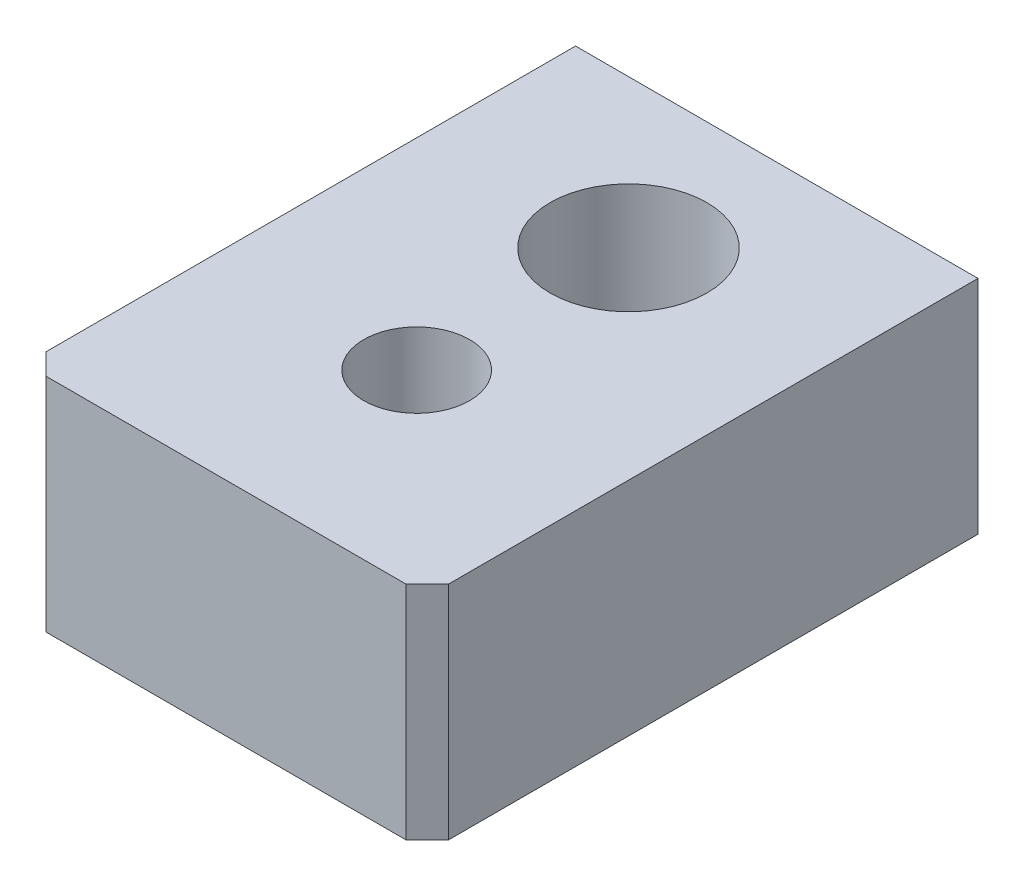
from build123d import *

# Parameters (mm, degrees)
SKETCH1_W                  = 5.5
SKETCH1_H                  = 6.24
EXTRUDE1_DEPTH             = 5
SKETCH6_W                  = 9.5
SKETCH6_H                  = 14
EXTRUDE2_DEPTH             = 5.23
F_3_7_3_7_DIAMETER_HOLE1_D = 3.7
SKETCH3_R                  = 1.25
CUT_EXTRUDE1_DEPTH         = 7.24
CHAMFER2_SIZE              = 0.5
SKETCH8_W                  = 9.5
SKETCH8_H                  = 1
EXTRUDE4_DEPTH             = 7.24


with BuildPart() as part:
    # Sketch1 → Extrude1 (new body, symmetric)
    with BuildSketch(Plane.XY):
        Rectangle(SKETCH1_W, SKETCH1_H)
    extrude(amount=EXTRUDE1_DEPTH, both=True)

    # Sketch6 → Extrude2 (add)
    with BuildSketch(Plane(origin=(0, 3.12, 0), x_dir=(1, 0, 0), z_dir=(0, 1, 0))):
        Rectangle(SKETCH6_W, SKETCH6_H)
    extrude(amount=-EXTRUDE2_DEPTH)

    # 3.7 _3.7_ Diameter Hole1 (through all)
    with Locations(Plane(origin=(0.72811331, -3.12, 5.297514906), x_dir=(1, 0, 0), z_dir=(0, -1, 0))):
        with Locations((-0.72811331, -7.797514906)):
            Hole(F_3_7_3_7_DIAMETER_HOLE1_D / 2)

    # Sketch3 → Cut-Extrude1 (cut, through all)
    with BuildSketch(Plane(origin=(0, -3.12, 0), x_dir=(-1, 0, 0), z_dir=(0, -1, 0))):
        with Locations(Location((0, -2.5, 0), (0, 0, 180))):  # turned: the seam where the file's is
            Circle(SKETCH3_R)
    extrude(amount=-CUT_EXTRUDE1_DEPTH, mode=Mode.SUBTRACT)

    # Chamfer2
    chamfer2_edges = [part.edges().sort_by_distance(p)[0] for p in [
        (4.75, 0.505, 7),
        (-4.75, 0.505, 7),
    ]]
    chamfer(chamfer2_edges, length=CHAMFER2_SIZE)

    # Sketch8 → Extrude4 (cut, through all)
    with BuildSketch(Plane.XZ.offset(3.12)):
        with Locations((0, -6.5)):
            Rectangle(SKETCH8_W, SKETCH8_H)
    extrude(amount=-EXTRUDE4_DEPTH, mode=Mode.SUBTRACT)


solid = part.part
